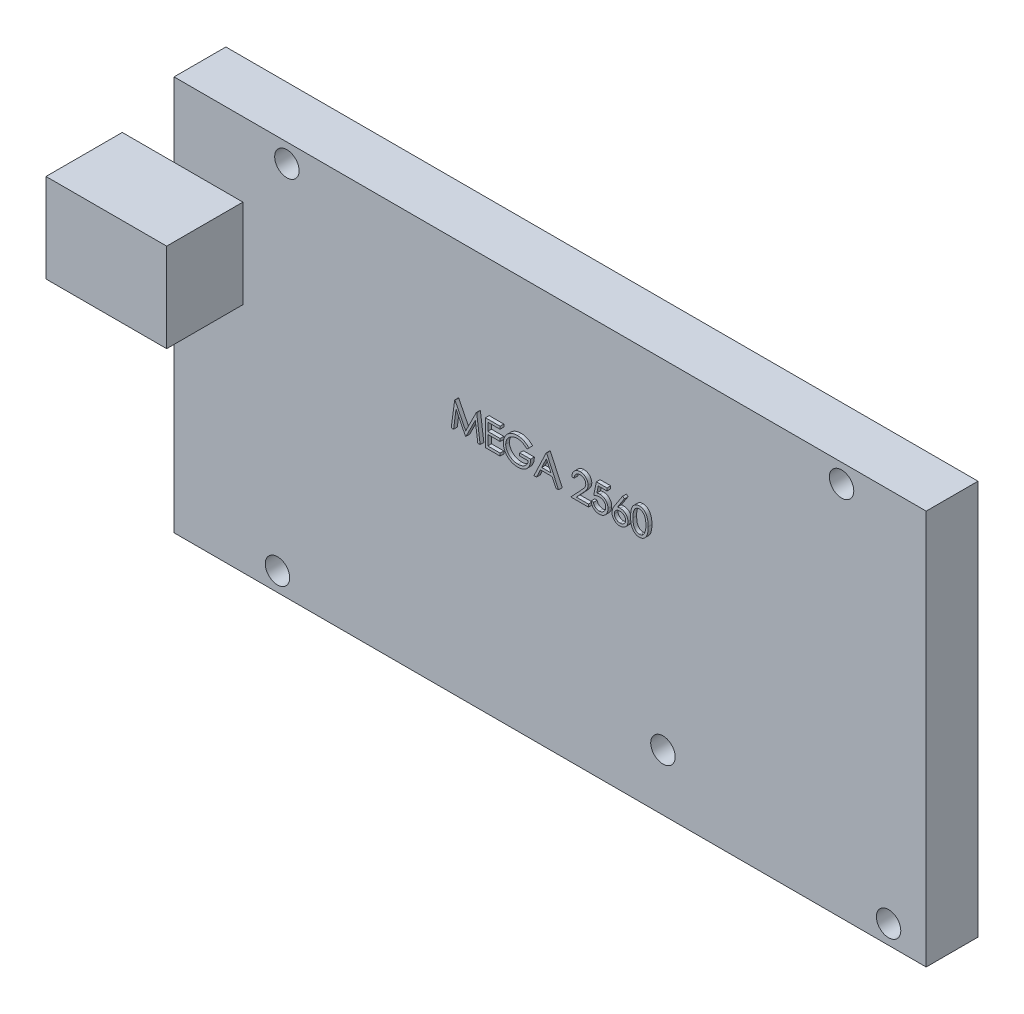
from build123d import *

# Parameters (mm, degrees)
SKETCH_1_W      = 101.6
SKETCH_1_H      = 53.34
SKETCH_1_R      = 1.65
EXTRUDE_1_DEPTH = 7
SKETCH_1_3_W    = 16.3
SKETCH_1_3_H    = 12
EXTRUDE_2_DEPTH = 10.3
EXTRUDE_3_DEPTH = 0.5


with BuildPart() as part:
    # 草图1 → 凸台-拉伸1 (new body)
    with BuildSketch(Plane.XY):
        with Locations((-50.8, 26.67)):
            Rectangle(SKETCH_1_W, SKETCH_1_H)
        with Locations((-87.63, 2.54)):
            Circle(SKETCH_1_R, mode=Mode.SUBTRACT)
        with Locations((-35.56, 7.62)):
            Circle(SKETCH_1_R, mode=Mode.SUBTRACT)
        with Locations((-5.08, 2.54)):
            Circle(SKETCH_1_R, mode=Mode.SUBTRACT)
        with Locations((-86.36, 50.8)):
            Circle(SKETCH_1_R, mode=Mode.SUBTRACT)
        with Locations((-11.43, 50.8)):
            Circle(SKETCH_1_R, mode=Mode.SUBTRACT)
    extrude(amount=-EXTRUDE_1_DEPTH)

    # 草图1<3> → 凸台-拉伸2 (add)
    with BuildSketch(Plane.XY):
        with Locations((-100.45, 37.34)):
            Rectangle(SKETCH_1_3_W, SKETCH_1_3_H)
    extrude(amount=EXTRUDE_2_DEPTH)

    # 草图2 → 凸台-拉伸3 (add)
    # profile 1 of 8: a face of its own
    with BuildSketch(Plane.XY):
        Polygon((-63.658447216, 31.493409381), (-63.196407953, 34.993409381), (-63.151536159, 34.993409381), (-61.706524139, 32.121614509), (-60.265017729, 34.993409381), (-60.219444812, 34.993409381), (-59.754601062, 31.493409381), (-60.07010587, 31.493409381), (-60.405242088, 34.011838868), (-61.668663562, 31.493409381), (-61.739476864, 31.493409381), (-63.007806191, 34.017447843), (-63.342241287, 31.493409381), align=None)
    # profile 2 of 8: a face of its own
    with BuildSketch(Plane.XY):
        Polygon((-59.036652344, 34.993409381), (-57.06229337, 34.993409381), (-57.06229337, 34.634435022), (-58.72254978, 34.634435022), (-58.72254978, 33.557511945), (-57.06229337, 33.557511945), (-57.06229337, 33.198537586), (-58.72254978, 33.198537586), (-58.72254978, 31.85238374), (-57.06229337, 31.85238374), (-57.06229337, 31.493409381), (-59.036652344, 31.493409381), align=None)
    # profile 3 of 8: a face of its own
    with BuildSketch(Plane.XY):
        with BuildLine():
            Line((-53.158447216, 34.396053612), (-53.427677986, 34.140845279))
            add(Edge.make_bspline(
                [(-53.427677986, 34.140845279), (-53.476396874, 34.186676142), (-53.57267292, 34.277245005), (-53.729633163, 34.394756), (-53.893396797, 34.4954221), (-54.063109294, 34.577328336), (-54.234567848, 34.642681097), (-54.405496624, 34.689209237), (-54.574142325, 34.718881774), (-54.686309544, 34.722430144), (-54.741580229, 34.724178612)],
                knots=[0, 0, 0, 0, 1.08915593, 2.152340314, 3.188132944, 4.216796309, 5.218260357, 6.173443236, 7.099959455, 8, 8, 8, 8], degree=3))
            add(Edge.make_bspline(
                [(-54.741580229, 34.724178612), (-54.775494929, 34.723765006), (-54.84323637, 34.722938867), (-54.943858314, 34.712394652), (-55.043424951, 34.697229788), (-55.141748325, 34.67528791), (-55.239019612, 34.64747885), (-55.334900504, 34.612693387), (-55.429569859, 34.572138143), (-55.52213594, 34.525275669), (-55.611876443, 34.473795823), (-55.696633279, 34.416747282), (-55.776946678, 34.355958492), (-55.851307103, 34.289907513), (-55.92014229, 34.219192648), (-55.985090662, 34.145129341), (-56.043867958, 34.065694123), (-56.096959123, 33.982348497), (-56.144320741, 33.896556308), (-56.186129395, 33.809143318), (-56.221226483, 33.720399463), (-56.248995938, 33.630213386), (-56.271906592, 33.539282796), (-56.288024199, 33.446978075), (-56.297110921, 33.35320039), (-56.298682701, 33.290403132), (-56.299472857, 33.258834061)],
                knots=[0, 0, 0, 0, 1.02818874, 2.053710826, 3.065248034, 4.081641283, 5.106893873, 6.131558223, 7.173050175, 8.228653731, 9.27666206, 10.308777013, 11.325269123, 12.329503258, 13.32196095, 14.316845687, 15.314881793, 16.315733098, 17.311955233, 18.285320748, 19.252783886, 20.203351036, 21.145449891, 22.095197417, 23.042428769, 24, 24, 24, 24], degree=3))
            add(Edge.make_bspline(
                [(-56.299472857, 33.258834061), (-56.298717139, 33.226563243), (-56.297207766, 33.16210973), (-56.287547447, 33.065915657), (-56.269619206, 32.971150255), (-56.245651497, 32.877502122), (-56.215670682, 32.784810874), (-56.178298015, 32.693478364), (-56.134032415, 32.603507973), (-56.082795863, 32.515710356), (-56.026609659, 32.430187333), (-55.963666578, 32.349627811), (-55.896805995, 32.272959033), (-55.823592095, 32.20188327), (-55.746372553, 32.134499373), (-55.662840277, 32.072663851), (-55.574637816, 32.015185628), (-55.481630605, 31.962789109), (-55.384827822, 31.915980573), (-55.285571069, 31.874356677), (-55.183543253, 31.84007734), (-55.079280564, 31.812139236), (-54.972907292, 31.789238938), (-54.863883489, 31.774506458), (-54.753010781, 31.763815627), (-54.678272149, 31.763033957), (-54.640618691, 31.76264015)],
                knots=[0, 0, 0, 0, 0.93586088, 1.869166235, 2.799637598, 3.729985548, 4.670839027, 5.622275134, 6.589130586, 7.576015415, 8.568469353, 9.55398029, 10.53834874, 11.515998671, 12.510579167, 13.508179873, 14.527009472, 15.561807829, 16.601455013, 17.643573243, 18.680854198, 19.719860599, 20.772568776, 21.833555941, 22.908541556, 24, 24, 24, 24], degree=3))
            add(Edge.make_bspline(
                [(-54.640618691, 31.76264015), (-54.595240343, 31.763588727), (-54.506132586, 31.76545141), (-54.375146143, 31.7799517), (-54.249343073, 31.802598493), (-54.129076869, 31.83576439), (-54.014207849, 31.878068065), (-53.904314907, 31.929063452), (-53.800263249, 31.990706511), (-53.701740075, 32.060280378), (-53.61098289, 32.13779521), (-53.529128766, 32.221439665), (-53.457483276, 32.310807732), (-53.394978577, 32.405373047), (-53.343269923, 32.505918352), (-53.300827128, 32.611950915), (-53.268293836, 32.723518427), (-53.254938861, 32.800610058), (-53.248190806, 32.839563227)],
                knots=[0, 0, 0, 0, 1.13008108, 2.219097802, 3.278683437, 4.311054135, 5.322181354, 6.324827112, 7.324222904, 8.330512327, 9.32562643, 10.293043162, 11.24128371, 12.174520618, 13.111833804, 14.052305215, 15.015860969, 16, 16, 16, 16], degree=3))
            Line((-53.248190806, 32.839563227), (-54.414857473, 32.839563227))
            Line((-54.414857473, 32.839563227), (-54.414857473, 33.198537586))
            Line((-54.414857473, 33.198537586), (-52.934088242, 33.198537586))
            add(Edge.make_bspline(
                [(-52.934088242, 33.198537586), (-52.93579409, 33.131630097), (-52.939132744, 33.000680056), (-52.962551659, 32.809709785), (-53.000368172, 32.629338092), (-53.052028484, 32.45937502), (-53.118903764, 32.300061427), (-53.200276292, 32.151235561), (-53.297448413, 32.01385888), (-53.406958855, 31.886809877), (-53.529858813, 31.773480664), (-53.662827433, 31.673874726), (-53.806084401, 31.589972111), (-53.959494208, 31.521711449), (-54.122554642, 31.468437454), (-54.295643022, 31.430665877), (-54.478524622, 31.408035914), (-54.603861299, 31.405144534), (-54.667962441, 31.403665791)],
                knots=[0, 0, 0, 0, 1.140356446, 2.231883559, 3.274166699, 4.278491846, 5.25512956, 6.21435461, 7.1637429, 8.11826594, 9.068280886, 10.0076534, 10.945064095, 11.891975133, 12.864533718, 13.863980011, 14.907571808, 16, 16, 16, 16], degree=3))
            add(Edge.make_bspline(
                [(-54.667962441, 31.403665791), (-54.707472576, 31.404234913), (-54.785399297, 31.405357403), (-54.900490225, 31.413334751), (-55.012407846, 31.425615327), (-55.121135854, 31.44416045), (-55.227074197, 31.466875104), (-55.329693782, 31.495961823), (-55.429385524, 31.529630523), (-55.526303509, 31.567926196), (-55.619568056, 31.612297853), (-55.709594573, 31.661607492), (-55.796880699, 31.715600853), (-55.880831864, 31.775211699), (-55.961885485, 31.839994159), (-56.039518929, 31.910078078), (-56.114166807, 31.985249198), (-56.16092727, 32.038628207), (-56.184488883, 32.065524766)],
                knots=[0, 0, 0, 0, 1.107784379, 2.184907829, 3.233506516, 4.263428166, 5.276301166, 6.270063455, 7.25232949, 8.225834625, 9.190232166, 10.146266622, 11.1027726, 12.066435141, 13.031522626, 14.010570082, 14.99756817, 16, 16, 16, 16], degree=3))
            add(Edge.make_bspline(
                [(-56.184488883, 32.065524766), (-56.218674815, 32.108195419), (-56.286479228, 32.192828436), (-56.373757384, 32.32842838), (-56.448158787, 32.468830241), (-56.508526609, 32.614424869), (-56.555664695, 32.765076082), (-56.589470948, 32.920591373), (-56.609278237, 33.081171003), (-56.612131775, 33.189836268), (-56.613575421, 33.244811625)],
                knots=[0, 0, 0, 0, 1.023165419, 2.029347347, 3.013907458, 3.994755782, 4.975994455, 5.96558838, 6.970761222, 8, 8, 8, 8], degree=3))
            add(Edge.make_bspline(
                [(-56.613575421, 33.244811625), (-56.613043183, 33.285977877), (-56.611985471, 33.367787185), (-56.599159955, 33.489244492), (-56.580758537, 33.608545184), (-56.553711483, 33.725591741), (-56.519615218, 33.840462333), (-56.477061732, 33.953210296), (-56.427516836, 34.063902168), (-56.36993134, 34.171776036), (-56.30584688, 34.275400449), (-56.23629666, 34.374358252), (-56.16029306, 34.466847317), (-56.07907726, 34.554038965), (-55.99168027, 34.634837812), (-55.898920846, 34.709991923), (-55.800727503, 34.779602109), (-55.696791324, 34.842571944), (-55.588663639, 34.899135564), (-55.476603638, 34.948724776), (-55.360645527, 34.989708091), (-55.241658049, 35.024481871), (-55.118740548, 35.050197011), (-54.992785012, 35.068845757), (-54.8631349, 35.081606357), (-54.77549887, 35.082632612), (-54.731063402, 35.083152971)],
                knots=[0, 0, 0, 0, 1.008945113, 2.00506715, 2.99143336, 3.967273523, 4.948097931, 5.927297278, 6.919902385, 7.919676788, 8.923139349, 9.905703106, 10.883022732, 11.856032218, 12.825136022, 13.798837087, 14.781400844, 15.773989409, 16.776158564, 17.77167057, 18.775803737, 19.789618931, 20.80898985, 21.851988756, 22.910860228, 24, 24, 24, 24], degree=3))
            add(Edge.make_bspline(
                [(-54.731063402, 35.083152971), (-54.694825159, 35.082573479), (-54.62296898, 35.081424415), (-54.516043247, 35.073459767), (-54.410770233, 35.060835886), (-54.306993843, 35.043609099), (-54.205067477, 35.020145409), (-54.104700771, 34.992067124), (-54.005748235, 34.959375302), (-53.908519986, 34.920386455), (-53.81236227, 34.87613283), (-53.716740429, 34.826319408), (-53.621981183, 34.770094403), (-53.527920202, 34.707290868), (-53.433964344, 34.63898745), (-53.341599702, 34.563230626), (-53.248596757, 34.48300787), (-53.188794943, 34.425325687), (-53.158447216, 34.396053612)],
                knots=[0, 0, 0, 0, 0.985871117, 1.954866573, 2.915460327, 3.869826059, 4.81536089, 5.759505086, 6.70452669, 7.649098992, 8.607881297, 9.583363685, 10.581137262, 11.603961102, 12.659522466, 13.73993555, 14.853081303, 16, 16, 16, 16], degree=3))
        make_face()
    # profile 4 of 8: a face of its own
    with BuildSketch(Plane.XY):
        Polygon((-50.780242088, 34.993409381), (-49.164857473, 31.493409381), (-49.506303787, 31.493409381), (-50.023731671, 32.615204253), (-51.610370293, 32.615204253), (-52.142521736, 31.493409381), (-52.485370293, 31.493409381), (-50.825113883, 34.993409381), align=None)
        Polygon((-50.806183594, 34.311217875), (-51.439997697, 32.974178612), (-50.189196415, 32.974178612), align=None, mode=Mode.SUBTRACT)
    # profile 5 of 8: a face of its own
    with BuildSketch(Plane.XY):
        with BuildLine():
            Line((-47.055883114, 33.916486304), (-47.369985678, 33.916486304))
            add(Edge.make_bspline(
                [(-47.369985678, 33.916486304), (-47.367938525, 33.958157192), (-47.363917971, 34.039997707), (-47.345089682, 34.159321613), (-47.318148804, 34.273376412), (-47.28005735, 34.381246326), (-47.232751073, 34.483885133), (-47.176021045, 34.580885149), (-47.108827195, 34.671876337), (-47.032620461, 34.756015181), (-46.949851822, 34.833202751), (-46.860545882, 34.899857994), (-46.766700855, 34.956175666), (-46.668601456, 35.003256907), (-46.565140892, 35.038596753), (-46.457258034, 35.064818393), (-46.344478898, 35.080594739), (-46.267638876, 35.082290524), (-46.228559396, 35.083152971)],
                knots=[0, 0, 0, 0, 1.10065271, 2.161652631, 3.183658789, 4.190468796, 5.17591951, 6.163126047, 7.15150782, 8.156236427, 9.156009102, 10.134482811, 11.092018607, 12.041330605, 13.001268258, 13.972401359, 14.968799086, 16, 16, 16, 16], degree=3))
            add(Edge.make_bspline(
                [(-46.228559396, 35.083152971), (-46.190181322, 35.082254514), (-46.114769777, 35.08048908), (-46.004707763, 35.06532805), (-45.899930468, 35.041582459), (-45.800642702, 35.008267042), (-45.707636637, 34.963482615), (-45.620213592, 34.909685076), (-45.537332782, 34.847465245), (-45.462725998, 34.774211432), (-45.394217919, 34.696009047), (-45.335115664, 34.612521143), (-45.2845025, 34.526291858), (-45.24231482, 34.436663656), (-45.211258681, 34.342792628), (-45.187680473, 34.246045425), (-45.17435306, 34.145420614), (-45.172307636, 34.077314058), (-45.171267729, 34.042688227)],
                knots=[0, 0, 0, 0, 1.111607364, 2.184268762, 3.212621178, 4.221274766, 5.211760367, 6.196651075, 7.1921475, 8.207485113, 9.220403448, 10.201281604, 11.166441695, 12.114753415, 13.065576456, 14.026450734, 14.996634279, 16, 16, 16, 16], degree=3))
            add(Edge.make_bspline(
                [(-45.171267729, 34.042688227), (-45.172960992, 33.993940393), (-45.176317803, 33.897300179), (-45.20503218, 33.755285316), (-45.249878691, 33.617691897), (-45.303876048, 33.506954595), (-45.358348492, 33.417721101), (-45.407435999, 33.344252396), (-45.464900811, 33.265146928), (-45.531579308, 33.180669591), (-45.606092181, 33.090158686), (-45.689114344, 32.99366889), (-45.781237826, 32.89219712), (-45.845896327, 32.822891519), (-45.879400742, 32.786979093)],
                knots=[0, 0, 0, 0, 1.184426356, 2.348067706, 3.509069118, 4.696110526, 5.333549288, 6.050745305, 6.844228056, 7.710549037, 8.667450064, 9.695053472, 10.805634456, 12, 12, 12, 12], degree=3))
            Line((-45.879400742, 32.786979093), (-46.755101864, 31.85238374))
            Line((-46.755101864, 31.85238374), (-45.126395934, 31.85238374))
            Line((-45.126395934, 31.85238374), (-45.126395934, 31.493409381))
            Line((-45.126395934, 31.493409381), (-47.504601062, 31.493409381))
            Line((-47.504601062, 31.493409381), (-46.147229268, 32.941927009))
            add(Edge.make_bspline(
                [(-46.147229268, 32.941927009), (-46.114181381, 32.976425316), (-46.050703154, 33.042689502), (-45.960920577, 33.139432463), (-45.880281589, 33.229182003), (-45.808264196, 33.311768552), (-45.74643069, 33.38840012), (-45.691558458, 33.456594823), (-45.647592867, 33.519349274), (-45.599877472, 33.592089887), (-45.55366349, 33.680902205), (-45.513951134, 33.789435894), (-45.489736286, 33.901163147), (-45.48683145, 33.976665184), (-45.485370293, 34.014643356)],
                knots=[0, 0, 0, 0, 1.329631726, 2.553950428, 3.673215718, 4.687767853, 5.603093632, 6.413772471, 7.123043292, 7.734684054, 8.834405432, 9.900288307, 10.943827018, 12, 12, 12, 12], degree=3))
            add(Edge.make_bspline(
                [(-45.485370293, 34.014643356), (-45.486006036, 34.038524754), (-45.487258962, 34.085590404), (-45.498316659, 34.154596163), (-45.515027165, 34.221160977), (-45.538972423, 34.285489596), (-45.570579163, 34.346935248), (-45.609052543, 34.405572728), (-45.653442607, 34.462261694), (-45.704793876, 34.515414992), (-45.761205396, 34.564096197), (-45.820799645, 34.607220283), (-45.88384975, 34.643259393), (-45.950089872, 34.672802891), (-46.019335341, 34.695978272), (-46.091720086, 34.712036851), (-46.167044103, 34.722119335), (-46.218477598, 34.723483507), (-46.244685197, 34.724178612)],
                knots=[0, 0, 0, 0, 0.991446411, 1.95395049, 2.89581595, 3.838931463, 4.798493298, 5.75982156, 6.748411868, 7.785213223, 8.824556874, 9.840280684, 10.836137867, 11.835679398, 12.848801643, 13.863922112, 14.911575587, 16, 16, 16, 16], degree=3))
            add(Edge.make_bspline(
                [(-46.244685197, 34.724178612), (-46.27205603, 34.72346358), (-46.325807826, 34.722059374), (-46.404726859, 34.71223671), (-46.480012636, 34.69529087), (-46.551854539, 34.672114196), (-46.620374125, 34.642655647), (-46.685238169, 34.605963902), (-46.746301059, 34.562180409), (-46.803677582, 34.512539853), (-46.856541561, 34.457272251), (-46.902988437, 34.395662288), (-46.943572451, 34.328834873), (-46.978981684, 34.256970322), (-47.007737375, 34.179416542), (-47.029710525, 34.096448838), (-47.047097372, 34.008427456), (-47.052905892, 33.947642371), (-47.055883114, 33.916486304)],
                knots=[0, 0, 0, 0, 1.031018746, 2.02475058, 2.990194455, 3.934040569, 4.864654155, 5.795059489, 6.735614925, 7.690564532, 8.649604399, 9.611025574, 10.590972636, 11.591080095, 12.624614302, 13.701020113, 14.821632451, 16, 16, 16, 16], degree=3))
        make_face()
    # profile 6 of 8: a face of its own
    with BuildSketch(Plane.XY):
        with BuildLine():
            Line((-42.613575421, 34.993409381), (-42.613575421, 34.634435022))
            Line((-42.613575421, 34.634435022), (-43.804080229, 34.634435022))
            Line((-43.804080229, 34.634435022), (-43.992681992, 33.713862106))
            add(Edge.make_bspline(
                [(-43.992681992, 33.713862106), (-43.955626118, 33.724092377), (-43.883836222, 33.743911911), (-43.777876361, 33.765917681), (-43.677284157, 33.779183125), (-43.612008787, 33.780994436), (-43.580422377, 33.78187092)],
                knots=[0, 0, 0, 0, 1.100273476, 2.13160584, 3.095893838, 4, 4, 4, 4], degree=3))
            add(Edge.make_bspline(
                [(-43.580422377, 33.78187092), (-43.541338637, 33.781024984), (-43.46449024, 33.779361663), (-43.352051293, 33.763389814), (-43.244718399, 33.738249899), (-43.142716029, 33.703129377), (-43.045855478, 33.658219644), (-42.955027917, 33.602119704), (-42.868870004, 33.536586372), (-42.78892741, 33.461241361), (-42.716403102, 33.378319744), (-42.652637112, 33.289161873), (-42.598474522, 33.194634211), (-42.554913767, 33.093833602), (-42.520129433, 32.987874448), (-42.496977438, 32.875641866), (-42.481560729, 32.758193746), (-42.479838343, 32.677889176), (-42.478960037, 32.636939029)],
                knots=[0, 0, 0, 0, 1.052922333, 2.070308379, 3.05430497, 4.020497103, 4.973039431, 5.925935799, 6.892292201, 7.88610001, 8.88166317, 9.857072816, 10.836096531, 11.812156883, 12.81219415, 13.836441305, 14.89672472, 16, 16, 16, 16], degree=3))
            add(Edge.make_bspline(
                [(-42.478960037, 32.636939029), (-42.479625112, 32.608416808), (-42.480946275, 32.551757821), (-42.487664862, 32.46761362), (-42.500600578, 32.385250787), (-42.517968303, 32.304658395), (-42.54051072, 32.225989023), (-42.567799774, 32.149017495), (-42.601195802, 32.074222888), (-42.637827177, 32.000897493), (-42.679073655, 31.930698986), (-42.724852163, 31.865049999), (-42.773217654, 31.802965718), (-42.825259039, 31.745111985), (-42.881460034, 31.691868967), (-42.941140001, 31.642920686), (-43.00382272, 31.597439355), (-43.070477963, 31.55727116), (-43.139620445, 31.520308204), (-43.212248663, 31.489984667), (-43.286709363, 31.462874138), (-43.364074239, 31.441264611), (-43.444168051, 31.424332056), (-43.527122827, 31.412831456), (-43.612503497, 31.404455018), (-43.670378509, 31.403930661), (-43.699613082, 31.403665791)],
                knots=[0, 0, 0, 0, 1.056347294, 2.098418968, 3.122841568, 4.141288669, 5.149314143, 6.15115421, 7.162517403, 8.180376062, 9.185164535, 10.17417709, 11.141909838, 12.097768115, 13.052685741, 14.0056014, 14.954263652, 15.917497458, 16.885230207, 17.854509472, 18.828990115, 19.81800267, 20.826176721, 21.857883937, 22.917946725, 24, 24, 24, 24], degree=3))
            add(Edge.make_bspline(
                [(-43.699613082, 31.403665791), (-43.734487262, 31.404356629), (-43.803098093, 31.405715772), (-43.90361866, 31.419934257), (-44.000333266, 31.440298173), (-44.092463367, 31.470934443), (-44.180834631, 31.509321738), (-44.264257348, 31.557837909), (-44.344863125, 31.612817013), (-44.419375161, 31.677697366), (-44.488531275, 31.748613048), (-44.550437784, 31.825570689), (-44.60557136, 31.907300131), (-44.653049107, 31.994198285), (-44.693547129, 32.086036816), (-44.725362117, 32.183159817), (-44.751040472, 32.285059821), (-44.761903892, 32.355213331), (-44.767421575, 32.390845279)],
                knots=[0, 0, 0, 0, 1.0467383, 2.05933395, 3.04377827, 4.011590433, 4.970194871, 5.932262533, 6.905835911, 7.896367577, 8.894135286, 9.877477877, 10.858688626, 11.851381753, 12.8477658, 13.868841284, 14.917554742, 16, 16, 16, 16], degree=3))
            Line((-44.767421575, 32.390845279), (-44.453319011, 32.390845279))
            add(Edge.make_bspline(
                [(-44.453319011, 32.390845279), (-44.445590454, 32.357468826), (-44.430735737, 32.293317431), (-44.398129989, 32.20318609), (-44.358264113, 32.122866866), (-44.310859765, 32.051297283), (-44.254309734, 31.988888286), (-44.189780305, 31.933271224), (-44.117432582, 31.883096094), (-44.037039353, 31.841273327), (-43.952226273, 31.805604574), (-43.863459063, 31.781852879), (-43.773154717, 31.765151986), (-43.712076347, 31.763480225), (-43.681383915, 31.76264015)],
                knots=[0, 0, 0, 0, 1.136247022, 2.183929868, 3.172523383, 4.106158343, 5.02341133, 5.958108904, 6.928429099, 7.938127109, 8.96079061, 9.975095812, 10.982467395, 12, 12, 12, 12], degree=3))
            add(Edge.make_bspline(
                [(-43.681383915, 31.76264015), (-43.651425471, 31.763460928), (-43.592437048, 31.765077047), (-43.505625662, 31.777516059), (-43.421812788, 31.79667363), (-43.341825431, 31.825343485), (-43.264263891, 31.860188203), (-43.191090121, 31.904903279), (-43.120187244, 31.956363298), (-43.05375911, 32.015319928), (-42.992919661, 32.080289622), (-42.93916354, 32.149767016), (-42.894386626, 32.223883862), (-42.856652517, 32.301357015), (-42.827999219, 32.383035572), (-42.807558237, 32.468536748), (-42.795555179, 32.558071728), (-42.793903999, 32.619141038), (-42.793062601, 32.650260343)],
                knots=[0, 0, 0, 0, 1.027316725, 2.022795036, 3.002884548, 3.971462791, 4.93288096, 5.914575861, 6.907176829, 7.935150275, 8.956128384, 9.956726525, 10.942570165, 11.921478529, 12.907843606, 13.90538589, 14.932640048, 16, 16, 16, 16], degree=3))
            add(Edge.make_bspline(
                [(-42.793062601, 32.650260343), (-42.79372108, 32.678336094), (-42.79500996, 32.733290383), (-42.805540531, 32.81368959), (-42.823857503, 32.889762632), (-42.849281383, 32.961876866), (-42.881560891, 33.030100308), (-42.921007203, 33.094503369), (-42.968360601, 33.154237202), (-43.022452489, 33.209329755), (-43.08171053, 33.26017463), (-43.147154273, 33.303518717), (-43.2174142, 33.339982634), (-43.291643799, 33.371450633), (-43.371608698, 33.394051378), (-43.45572533, 33.411019264), (-43.544902038, 33.420834626), (-43.605872726, 33.422196515), (-43.637213242, 33.422896561)],
                knots=[0, 0, 0, 0, 1.045622112, 2.046656509, 3.013763289, 3.955457236, 4.890082067, 5.820317437, 6.762574623, 7.722996705, 8.69280354, 9.665887285, 10.63943826, 11.638615906, 12.663482002, 13.728887084, 14.832589034, 16, 16, 16, 16], degree=3))
            add(Edge.make_bspline(
                [(-43.637213242, 33.422896561), (-43.664342171, 33.422315969), (-43.720356526, 33.421117196), (-43.806279353, 33.412290699), (-43.896571076, 33.398051405), (-43.990885571, 33.378465157), (-44.089506079, 33.352834081), (-44.19222448, 33.32211958), (-44.299256747, 33.285397581), (-44.371374471, 33.257665367), (-44.408447216, 33.243409381)],
                knots=[0, 0, 0, 0, 0.817624296, 1.688186739, 2.600797293, 3.572016777, 4.590301741, 5.671205678, 6.80286297, 8, 8, 8, 8], degree=3))
            Line((-44.408447216, 33.243409381), (-44.049472857, 34.993409381))
            Line((-44.049472857, 34.993409381), (-42.613575421, 34.993409381))
        make_face()
    # profile 7 of 8: a face of its own
    with BuildSketch(Plane.XY):
        with BuildLine():
            Line((-40.504601062, 35.083152971), (-40.262714043, 34.893148964))
            Line((-40.262714043, 34.893148964), (-41.187493691, 33.478986304))
            add(Edge.make_bspline(
                [(-41.187493691, 33.478986304), (-41.125923414, 33.488800165), (-41.005823627, 33.50794321), (-40.884257728, 33.511101155), (-40.825013723, 33.51264015)],
                knots=[0, 0, 0, 0, 1.025318673, 2, 2, 2, 2], degree=3))
            add(Edge.make_bspline(
                [(-40.825013723, 33.51264015), (-40.789441226, 33.511684039), (-40.719417826, 33.509801961), (-40.616611024, 33.495318111), (-40.517822088, 33.472492999), (-40.423460476, 33.439220743), (-40.333187494, 33.396718388), (-40.246485098, 33.345779518), (-40.164983087, 33.283773838), (-40.087631908, 33.214508882), (-40.017404811, 33.137791897), (-39.955228755, 33.056390561), (-39.903001964, 32.97038968), (-39.860628042, 32.879832814), (-39.827723163, 32.784859554), (-39.803735518, 32.685591415), (-39.789555925, 32.581959943), (-39.787630435, 32.511481768), (-39.786652344, 32.475681016)],
                knots=[0, 0, 0, 0, 1.04369286, 2.054478336, 3.041073146, 4.015093852, 4.984733326, 5.965804835, 6.960378782, 7.985147595, 9.009457201, 10.008161701, 10.986880575, 11.956520048, 12.937015923, 13.931873656, 14.949455224, 16, 16, 16, 16], degree=3))
            add(Edge.make_bspline(
                [(-39.786652344, 32.475681016), (-39.788075449, 32.426701312), (-39.790875783, 32.330320846), (-39.818779579, 32.189944139), (-39.862139224, 32.056211624), (-39.924116752, 31.931258453), (-40.001099135, 31.815255883), (-40.094976728, 31.712470418), (-40.202420216, 31.62080038), (-40.323907014, 31.544143761), (-40.454649978, 31.48154071), (-40.592001976, 31.436575468), (-40.734629122, 31.408891999), (-40.83143373, 31.405421396), (-40.880402344, 31.403665791)],
                knots=[0, 0, 0, 0, 1.031375318, 2.029502543, 3.004789286, 3.987476834, 4.960371455, 5.9300674, 6.912260825, 7.929083631, 8.949397511, 9.960523116, 10.96833055, 12, 12, 12, 12], degree=3))
            add(Edge.make_bspline(
                [(-40.880402344, 31.403665791), (-40.927499045, 31.405193997), (-41.020789363, 31.408221105), (-41.158022157, 31.435187043), (-41.289885175, 31.478894146), (-41.415454556, 31.539108424), (-41.531775169, 31.615166307), (-41.635840805, 31.706728586), (-41.72713258, 31.811838051), (-41.8031072, 31.930478399), (-41.863365932, 32.057968356), (-41.908555858, 32.190905513), (-41.934952101, 32.328805494), (-41.938640658, 32.422286634), (-41.940498498, 32.46937092)],
                knots=[0, 0, 0, 0, 1.012016664, 2.004627821, 2.994792927, 3.992885782, 4.990978636, 5.973936114, 6.964471063, 7.975201453, 8.993600317, 9.990122807, 10.98767138, 12, 12, 12, 12], degree=3))
            add(Edge.make_bspline(
                [(-41.940498498, 32.46937092), (-41.939317053, 32.505415503), (-41.936904768, 32.579011655), (-41.920061378, 32.690475683), (-41.892996583, 32.804526764), (-41.862686337, 32.901280958), (-41.830660727, 32.98054248), (-41.804008187, 33.044445971), (-41.770834191, 33.110207044), (-41.73546081, 33.18008068), (-41.694703941, 33.252266113), (-41.650388292, 33.327969782), (-41.601288641, 33.40598771), (-41.566868478, 33.458931905), (-41.549272537, 33.485997522)],
                knots=[0, 0, 0, 0, 1.173818275, 2.396712641, 3.66331629, 4.989737886, 5.693666774, 6.447286557, 7.243889047, 8.091586357, 8.998013824, 9.943181721, 10.948533338, 12, 12, 12, 12], degree=3))
            Line((-41.549272537, 33.485997522), (-40.504601062, 35.083152971))
        make_face()
        with BuildLine():
            add(Edge.make_bspline(
                [(-40.890919171, 33.153665791), (-40.917581416, 33.152887748), (-40.969660526, 33.151368002), (-41.04606794, 33.14254275), (-41.118381192, 33.125923685), (-41.187558325, 33.104757353), (-41.252306028, 33.075654293), (-41.313094868, 33.040302494), (-41.37015992, 32.998681316), (-41.422903472, 32.951380405), (-41.470723135, 32.899592372), (-41.511904266, 32.84412285), (-41.547426666, 32.786308647), (-41.576308485, 32.725666705), (-41.598798561, 32.662220205), (-41.615066812, 32.596260956), (-41.624120563, 32.527346649), (-41.625626794, 32.480614147), (-41.626395934, 32.456750727)],
                knots=[0, 0, 0, 0, 1.129588631, 2.206414736, 3.251139165, 4.268635594, 5.265702196, 6.250456724, 7.242448911, 8.251968645, 9.246821453, 10.222880186, 11.173611482, 12.116736599, 13.062300278, 14.020270554, 14.989073742, 16, 16, 16, 16], degree=3))
            add(Edge.make_bspline(
                [(-41.626395934, 32.456750727), (-41.625769573, 32.433100747), (-41.624541371, 32.386726658), (-41.613389051, 32.318387478), (-41.596353969, 32.25262257), (-41.571013573, 32.189770971), (-41.540786685, 32.128874653), (-41.500881361, 32.072139367), (-41.456664575, 32.016119297), (-41.403810641, 31.965117826), (-41.347087278, 31.917661202), (-41.286486076, 31.876180948), (-41.223326116, 31.840694775), (-41.156754694, 31.812883677), (-41.08771631, 31.79005939), (-41.015635756, 31.773997911), (-40.9404629, 31.764917385), (-40.889540962, 31.763409191), (-40.863575421, 31.76264015)],
                knots=[0, 0, 0, 0, 0.989467248, 1.94019797, 2.891935182, 3.827694429, 4.772920941, 5.730924762, 6.725747692, 7.756678648, 8.79901574, 9.819492441, 10.826891316, 11.826466727, 12.835195252, 13.867842842, 14.912794438, 16, 16, 16, 16], degree=3))
            add(Edge.make_bspline(
                [(-40.863575421, 31.76264015), (-40.837609923, 31.763409252), (-40.786688068, 31.764917564), (-40.711514608, 31.773997232), (-40.639436289, 31.79006188), (-40.570389781, 31.812874651), (-40.50384835, 31.84072826), (-40.440743628, 31.87596018), (-40.380715535, 31.917916298), (-40.323954935, 31.965036726), (-40.271320997, 32.016409578), (-40.226043718, 32.0716393), (-40.187360485, 32.129333196), (-40.155926298, 32.189531086), (-40.130865006, 32.252660573), (-40.113743539, 32.318377297), (-40.10261425, 32.386729323), (-40.101382884, 32.433101648), (-40.100754909, 32.456750727)],
                knots=[0, 0, 0, 0, 1.087397944, 2.132534446, 3.165364764, 4.174271784, 5.174024072, 6.181601208, 7.194203697, 8.236725232, 9.267838612, 10.269026844, 11.221737037, 12.171628256, 13.107553087, 14.05945871, 15.010357665, 16, 16, 16, 16], degree=3))
            add(Edge.make_bspline(
                [(-40.100754909, 32.456750727), (-40.101305202, 32.480645278), (-40.102385248, 32.527542511), (-40.114601196, 32.596230129), (-40.13154357, 32.662555335), (-40.157126601, 32.726101284), (-40.190363146, 32.786617211), (-40.230846553, 32.844408812), (-40.277679123, 32.89991916), (-40.331776663, 32.951481968), (-40.390666897, 32.998629046), (-40.453282482, 33.040248602), (-40.518790456, 33.075373579), (-40.587124398, 33.104680681), (-40.659067281, 33.125830155), (-40.73345762, 33.142483399), (-40.811246863, 33.151345416), (-40.864023471, 33.152882481), (-40.890919171, 33.153665791)],
                knots=[0, 0, 0, 0, 0.978206639, 1.919901502, 2.851605144, 3.780102724, 4.718870031, 5.675451981, 6.667674623, 7.690630536, 8.733308323, 9.756129687, 10.767539656, 11.776269907, 12.797430371, 13.836405707, 14.897401972, 16, 16, 16, 16], degree=3))
        make_face(mode=Mode.SUBTRACT)
    # profile 8 of 8: a face of its own
    with BuildSketch(Plane.XY):
        with BuildLine():
            add(Edge.make_bspline(
                [(-39.427677986, 33.242007138), (-39.427349967, 33.298104525), (-39.426712787, 33.40707451), (-39.419624366, 33.565859152), (-39.407849024, 33.714819441), (-39.391711651, 33.853962507), (-39.372073671, 33.983324271), (-39.345858184, 34.102559028), (-39.316045382, 34.212218635), (-39.281492936, 34.312660683), (-39.242505147, 34.405238386), (-39.200070886, 34.491663588), (-39.152506092, 34.57180552), (-39.102529179, 34.64694331), (-39.048117107, 34.715847005), (-38.990818317, 34.779489668), (-38.928396441, 34.836400418), (-38.862973432, 34.888246721), (-38.793956968, 34.933696192), (-38.723314302, 34.973728931), (-38.650559196, 35.007928798), (-38.575493013, 35.034819234), (-38.498790455, 35.057030081), (-38.420183388, 35.072219028), (-38.339542024, 35.081775937), (-38.28511059, 35.082689605), (-38.25750571, 35.083152971)],
                knots=[0, 0, 0, 0, 1.646270934, 3.197905019, 4.663502075, 6.030701355, 7.308322542, 8.50163776, 9.611534131, 10.641858119, 11.616356847, 12.558055219, 13.465016945, 14.349605745, 15.204443733, 16.039544428, 16.859896111, 17.680448484, 18.487036065, 19.28249412, 20.06191084, 20.843045899, 21.620316918, 22.403196591, 23.190181807, 24, 24, 24, 24], degree=3))
            add(Edge.make_bspline(
                [(-38.25750571, 35.083152971), (-38.229670231, 35.082665156), (-38.174314222, 35.081695045), (-38.092473847, 35.072371102), (-38.012524166, 35.056899979), (-37.934806027, 35.034979005), (-37.85868104, 35.007783328), (-37.784744633, 34.973696211), (-37.712537551, 34.934017343), (-37.643207264, 34.887393466), (-37.575992648, 34.83541119), (-37.512544685, 34.776648521), (-37.452857599, 34.711698802), (-37.396182294, 34.641256938), (-37.344126697, 34.563971853), (-37.294553265, 34.481187743), (-37.250181229, 34.391456879), (-37.207446553, 34.296276411), (-37.170559567, 34.193012752), (-37.137293321, 34.082247991), (-37.110414353, 33.962673805), (-37.088025081, 33.834917559), (-37.070680185, 33.698510076), (-37.058047542, 33.553743761), (-37.051374457, 33.40052337), (-37.050117756, 33.295765521), (-37.049472857, 33.242007138)],
                knots=[0, 0, 0, 0, 0.810914788, 1.612654377, 2.396697861, 3.181598691, 3.963628158, 4.749916497, 5.551656086, 6.361998678, 7.18212741, 8.025565596, 8.878627764, 9.750805457, 10.657531673, 11.591944965, 12.560506719, 13.57287815, 14.630710178, 15.753379473, 16.941251878, 18.199788006, 19.531962791, 20.947069417, 22.433333509, 24, 24, 24, 24], degree=3))
            add(Edge.make_bspline(
                [(-37.049472857, 33.242007138), (-37.050124442, 33.18848323), (-37.051394028, 33.084194078), (-37.057972735, 32.931663102), (-37.070931366, 32.787665059), (-37.087141354, 32.651854597), (-37.109592317, 32.524796978), (-37.137197483, 32.406052529), (-37.167847806, 32.295108458), (-37.2056826, 32.192873646), (-37.247093311, 32.097921923), (-37.292148507, 32.009254775), (-37.340418333, 31.926088482), (-37.393007078, 31.849088735), (-37.449060491, 31.777710078), (-37.50977828, 31.713212456), (-37.573448865, 31.654041784), (-37.640861281, 31.601390156), (-37.711272832, 31.555305352), (-37.783231909, 31.514091501), (-37.858015292, 31.480858806), (-37.933928245, 31.452323765), (-38.012056611, 31.430523313), (-38.092303002, 31.415449458), (-38.174259238, 31.404877609), (-38.229660803, 31.404071129), (-38.25750571, 31.403665791)],
                knots=[0, 0, 0, 0, 1.561518951, 3.042555995, 4.452378317, 5.7783523, 7.031515105, 8.214008947, 9.334062868, 10.386615937, 11.391082383, 12.354592575, 13.286541444, 14.194233754, 15.072674879, 15.931287219, 16.775624067, 17.606195743, 18.42308326, 19.229000347, 20.022332153, 20.807536673, 21.593273796, 22.3848459, 23.188221202, 24, 24, 24, 24], degree=3))
            add(Edge.make_bspline(
                [(-38.25750571, 31.403665791), (-38.285109824, 31.404132147), (-38.339539749, 31.405051709), (-38.420192174, 31.41456544), (-38.498474618, 31.429860943), (-38.574773372, 31.451277548), (-38.649479887, 31.477492384), (-38.721576173, 31.511646068), (-38.791863857, 31.550980136), (-38.860155413, 31.595775558), (-38.925167574, 31.647097241), (-38.987266179, 31.70386153), (-39.044891198, 31.767484941), (-39.098525294, 31.836962864), (-39.149499382, 31.911656106), (-39.196388756, 31.992584479), (-39.23975961, 32.07942709), (-39.2794031, 32.172745001), (-39.314551764, 32.273899929), (-39.345599472, 32.384049107), (-39.370113629, 32.504164743), (-39.391096585, 32.63328211), (-39.408020968, 32.771956041), (-39.419575293, 32.920261819), (-39.426716608, 33.078107028), (-39.427351679, 33.186376802), (-39.427677986, 33.242007138)],
                knots=[0, 0, 0, 0, 0.810891512, 1.598919785, 2.382837074, 3.152667961, 3.926044502, 4.706494248, 5.493654104, 6.291793342, 7.103789334, 7.925228297, 8.761435821, 9.622817696, 10.50288917, 11.416980706, 12.369136599, 13.353924996, 14.394355917, 15.514179734, 16.714354668, 17.994756427, 19.357759367, 20.818452758, 22.365282078, 24, 24, 24, 24], degree=3))
        make_face()
        with BuildLine():
            add(Edge.make_bspline(
                [(-39.113575421, 33.243409381), (-39.113455974, 33.196660682), (-39.113224151, 33.105930638), (-39.10716795, 32.974087377), (-39.098917718, 32.851117048), (-39.088276421, 32.736863511), (-39.072473473, 32.631713499), (-39.054766685, 32.534943816), (-39.033218595, 32.447066579), (-39.007723577, 32.367478768), (-38.978684481, 32.294829699), (-38.946978617, 32.227228484), (-38.912917894, 32.163876548), (-38.874798743, 32.105342939), (-38.83328368, 32.051436775), (-38.789310421, 32.001203943), (-38.741237837, 31.956406962), (-38.674734094, 31.902680107), (-38.58693762, 31.847160973), (-38.476317165, 31.798814883), (-38.362648714, 31.768432427), (-38.285497464, 31.764568671), (-38.246988883, 31.76264015)],
                knots=[0, 0, 0, 0, 1.459021318, 2.831673884, 4.118529203, 5.306027144, 6.411944654, 7.436330062, 8.375795394, 9.233974572, 10.042671642, 10.816086306, 11.563610507, 12.285937304, 12.993564865, 13.685989202, 14.367179055, 15.041617293, 16.353048772, 17.594441528, 18.799311195, 20, 20, 20, 20], degree=3))
            add(Edge.make_bspline(
                [(-38.246988883, 31.76264015), (-38.208231211, 31.764237931), (-38.130795888, 31.767430194), (-38.017662093, 31.798228931), (-37.907831823, 31.844698471), (-37.821759883, 31.899645976), (-37.756277339, 31.951974306), (-37.709360349, 31.996588954), (-37.666298301, 32.046544821), (-37.625456226, 32.100444117), (-37.58799715, 32.159316601), (-37.553934012, 32.222879177), (-37.522850665, 32.291308355), (-37.505141619, 32.339078094), (-37.496087441, 32.363501529)],
                knots=[0, 0, 0, 0, 1.353760809, 2.704726607, 4.075137775, 5.516104923, 6.260822281, 7.007110065, 7.778089737, 8.566572457, 9.372053459, 10.217411131, 11.088608312, 12, 12, 12, 12], degree=3))
            add(Edge.make_bspline(
                [(-37.496087441, 32.363501529), (-37.485535673, 32.394731268), (-37.464111059, 32.458141032), (-37.436499285, 32.556504684), (-37.414753886, 32.659707448), (-37.39519052, 32.767132565), (-37.381837464, 32.879572266), (-37.371089651, 32.99667865), (-37.364758964, 33.118540012), (-37.363974213, 33.201335003), (-37.363575421, 33.243409381)],
                knots=[0, 0, 0, 0, 0.884706709, 1.796334032, 2.740027952, 3.714592787, 4.726048262, 5.777819803, 6.87074269, 8, 8, 8, 8], degree=3))
            add(Edge.make_bspline(
                [(-37.363575421, 33.243409381), (-37.364125611, 33.285476954), (-37.365201898, 33.367770118), (-37.369315886, 33.488288299), (-37.379939461, 33.60275606), (-37.391738579, 33.711666533), (-37.409135801, 33.814416835), (-37.427893607, 33.911867141), (-37.45309482, 34.002810165), (-37.480014595, 34.088669747), (-37.51082499, 34.168470402), (-37.544740724, 34.242584188), (-37.580962483, 34.311368913), (-37.620304724, 34.374635854), (-37.662300407, 34.432668397), (-37.708057956, 34.484302992), (-37.755762329, 34.53113996), (-37.822579515, 34.584602529), (-37.910053804, 34.639114225), (-38.018899452, 34.689279984), (-38.132170096, 34.718088277), (-38.20874355, 34.722149964), (-38.246988883, 34.724178612)],
                knots=[0, 0, 0, 0, 1.31362396, 2.569729283, 3.763502607, 4.902122613, 5.988968491, 7.01645872, 7.998833611, 8.933434873, 9.825090667, 10.667526885, 11.477055099, 12.250526234, 12.991942729, 13.710640831, 14.402115721, 15.076753259, 16.378508321, 17.609869233, 18.806226677, 20, 20, 20, 20], degree=3))
            add(Edge.make_bspline(
                [(-38.246988883, 34.724178612), (-38.285699475, 34.722147165), (-38.363191181, 34.718080571), (-38.477639135, 34.689387318), (-38.587343487, 34.639374352), (-38.674586462, 34.584421979), (-38.741450248, 34.532083668), (-38.788532942, 34.486697214), (-38.832679114, 34.437050959), (-38.873346814, 34.382649044), (-38.911436097, 34.324183677), (-38.94641711, 34.261194912), (-38.977934439, 34.193363548), (-39.007018976, 34.120747113), (-39.032591764, 34.041166168), (-39.053685727, 33.953397175), (-39.07317278, 33.856935283), (-39.086968049, 33.751215775), (-39.099231805, 33.636933622), (-39.107113153, 33.513656303), (-39.11324441, 33.381591923), (-39.113462874, 33.290392764), (-39.113575421, 33.243409381)],
                knots=[0, 0, 0, 0, 1.207732386, 2.417664972, 3.655092373, 4.956220595, 5.625982001, 6.301752483, 6.994047911, 7.697131622, 8.419323945, 9.170223765, 9.943494443, 10.752040957, 11.610060368, 12.549350801, 13.567764191, 14.679664412, 15.874934091, 17.154273443, 18.533957287, 20, 20, 20, 20], degree=3))
        make_face(mode=Mode.SUBTRACT)
    extrude(amount=EXTRUDE_3_DEPTH)


solid = part.part
